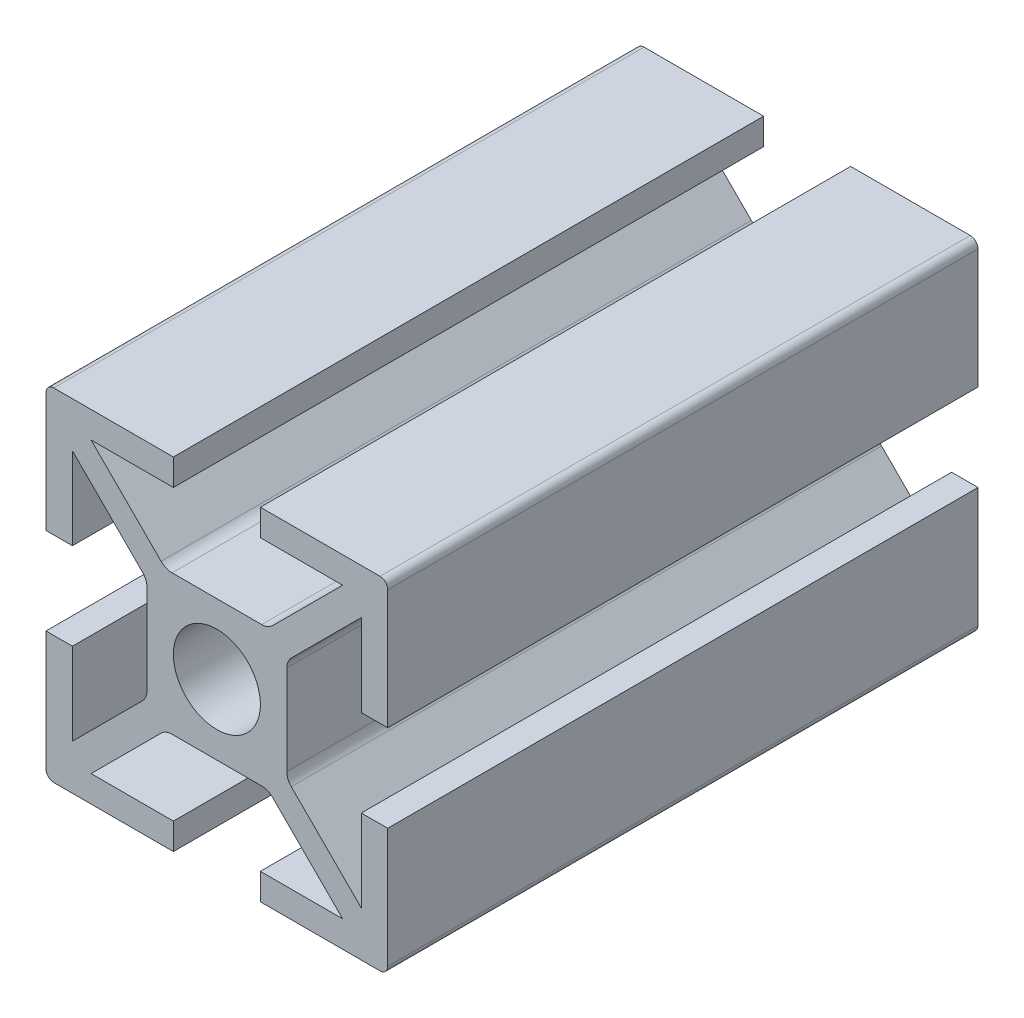
from build123d import *

# Parameters (mm, degrees)
EXTRUSION1_DEPTH        = 38
ESQUISSE2_R             = 2.8
ENL_V_MAT_EXTRU_1_DEPTH = 39
CONG_1_R                = 0.5
CONG_2_R                = 1


with BuildPart() as part:
    # Esquisse1 → Extrusion1 (new body)
    with BuildSketch(Plane.XY):
        Polygon((-2.8, 11), (-2.8, 9.3), (-8.097918472, 9.3), (-3.297918472, 4.5), (3.297918472, 4.5), (8.097918472, 9.3), (2.8, 9.3), (2.8, 11), (11, 11), (11, 2.8), (9.3, 2.8), (9.3, 8.097918472), (4.5, 3.297918472), (4.5, -3.297918472), (9.3, -8.097918472), (9.3, -2.8), (11, -2.8), (11, -11), (2.8, -11), (2.8, -9.3), (8.097918472, -9.3), (3.297918472, -4.5), (-3.297918472, -4.5), (-8.097918472, -9.3), (-2.8, -9.3), (-2.8, -11), (-11, -11), (-11, -2.8), (-9.3, -2.8), (-9.3, -8.097918472), (-4.5, -3.297918472), (-4.5, 3.297918472), (-9.3, 8.097918472), (-9.3, 2.8), (-11, 2.8), (-11, 11), align=None)
    extrude(amount=EXTRUSION1_DEPTH)

    # Esquisse2 → Enlèv. mat.-Extru.1 (cut, through all)
    with BuildSketch(Plane(origin=(0, 0, 0), x_dir=(-1, 0, 0), z_dir=(0, 0, -1))):
        Circle(ESQUISSE2_R)
    extrude(amount=-ENL_V_MAT_EXTRU_1_DEPTH, mode=Mode.SUBTRACT)

    # Congé1
    cong_1_edges = [part.edges().sort_by_distance(p)[0] for p in [
        (-11, 11, 19),
        (11, 11, 19),
        (11, -11, 19),
        (-11, -11, 19),
    ]]
    fillet(cong_1_edges, radius=CONG_1_R)

    # Congé2
    cong_2_edges = [part.edges().sort_by_distance(p)[0] for p in [
        (-4.5, -3.297918472, 19),
        (-4.5, 3.297918472, 19),
        (-3.297918472, 4.5, 19),
        (3.297918472, 4.5, 19),
        (4.5, 3.297918472, 19),
        (4.5, -3.297918472, 19),
        (3.297918472, -4.5, 19),
        (-3.297918472, -4.5, 19),
    ]]
    fillet(cong_2_edges, radius=CONG_2_R)


solid = part.part
